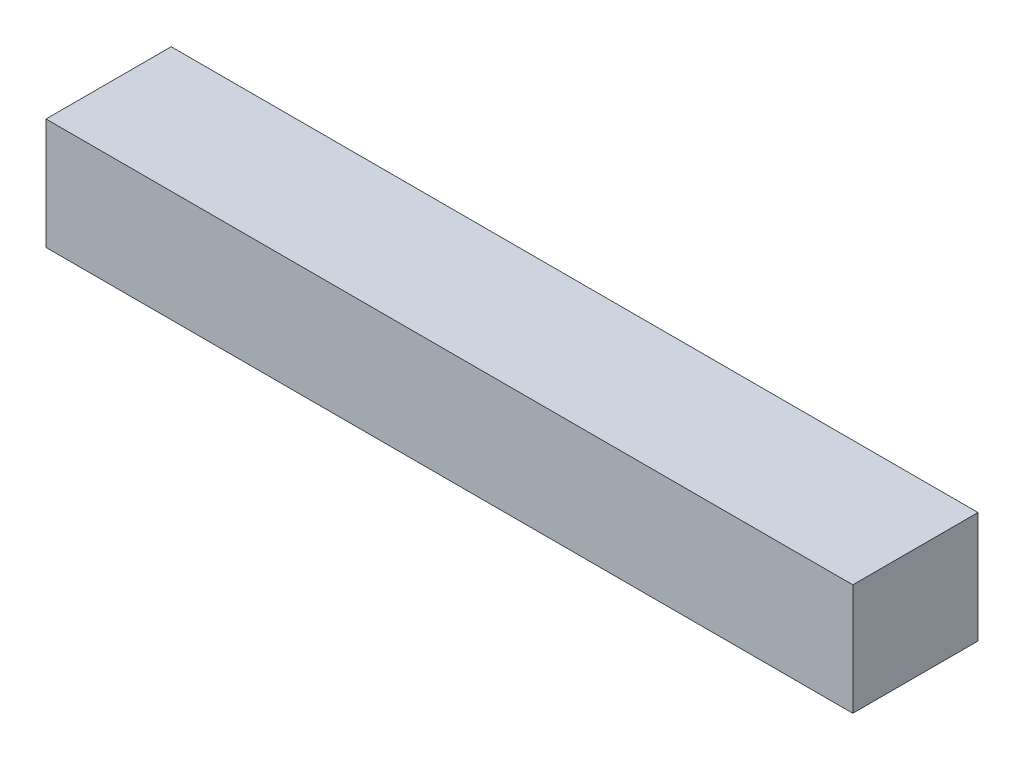
from build123d import *

# Parameters (mm, degrees)
SKETCH2_W           = 58
SKETCH2_H           = 9
BOSS_EXTRUDE1_DEPTH = 8


with BuildPart() as part:
    # Sketch2 → Boss-Extrude1 (new body)
    with BuildSketch(Plane(origin=(0, 0, 0), x_dir=(1, 0, 0), z_dir=(0, 1, 0))):
        Rectangle(SKETCH2_W, SKETCH2_H)
    extrude(amount=BOSS_EXTRUDE1_DEPTH)


solid = part.part
